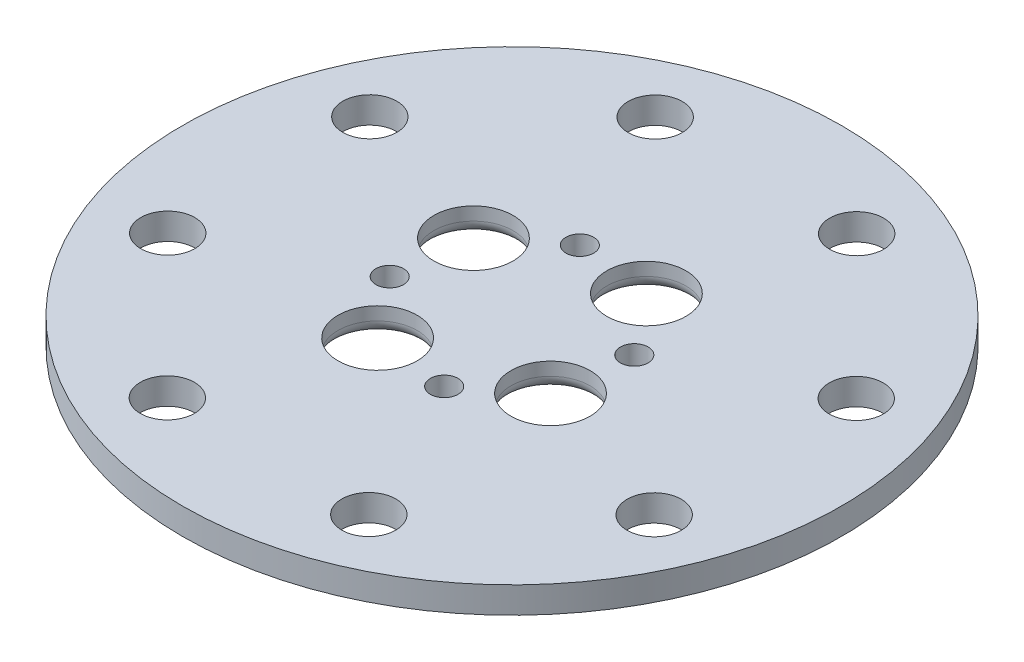
from build123d import *

# Parameters (mm, degrees)
SKETCH1_R           = 25
BOSS_EXTRUDE1_DEPTH = 2
SKETCH2_R           = 1.05
SKETCH2_R_2         = 3
CUT_EXTRUDE1_DEPTH  = 3
FILLET1_R           = 1
SKETCH4_R           = 2.05
CUT_EXTRUDE3_DEPTH  = 3


with BuildPart() as part:
    # Sketch1 → Boss-Extrude1 (new body)
    with BuildSketch(Plane(origin=(0, 0, 0), x_dir=(1, 0, 0), z_dir=(0, 1, 0))):
        Circle(SKETCH1_R)
    extrude(amount=BOSS_EXTRUDE1_DEPTH)

    # Sketch2 → Cut-Extrude1 (cut, through all)
    with BuildSketch(Plane(origin=(0, 2, 0), x_dir=(1, 0, 0), z_dir=(0, 1, 0))):
        with Locations((-2.066368974, 7.209723938)):
            Circle(SKETCH2_R)
        with Locations((7.209723938, 2.066368974)):
            Circle(SKETCH2_R)
        with Locations((2.066368974, -7.209723938)):
            Circle(SKETCH2_R)
        with Locations((-7.209723938, -2.066368974)):
            Circle(SKETCH2_R)
        with Locations((-3.636901173, -6.559188201)):
            Circle(SKETCH2_R_2)
        with Locations((-6.559188201, 3.636901173)):
            Circle(SKETCH2_R_2)
        with Locations((3.636901173, 6.559188201)):
            Circle(SKETCH2_R_2)
        with Locations((6.559188201, -3.636901173)):
            Circle(SKETCH2_R_2)
    extrude(amount=-CUT_EXTRUDE1_DEPTH, mode=Mode.SUBTRACT)

    # Fillet1
    fillet1_edges = [part.edges().sort_by_distance(p)[0] for p in [
        (-6.636901173, 0, 6.559188201),
        (-9.559188201, 0, -3.636901173),
        (0.636901173, 0, -6.559188201),
        (3.559188201, 0, 3.636901173),
    ]]
    fillet(fillet1_edges, radius=FILLET1_R)

    # Sketch4 → Cut-Extrude3 (cut, through all)
    with BuildSketch(Plane.XZ):
        with Locations((-18.488747294, 7.626678405)):
            Circle(SKETCH4_R)
        with Locations((-7.680642569, 18.466394605)):
            Circle(SKETCH4_R)
        with Locations((7.626678405, 18.488747294)):
            Circle(SKETCH4_R)
        with Locations((18.466394605, 7.680642569)):
            Circle(SKETCH4_R)
        with Locations((18.488747294, -7.626678405)):
            Circle(SKETCH4_R)
        with Locations((7.680642569, -18.466394605)):
            Circle(SKETCH4_R)
        with Locations((-7.626678405, -18.488747294)):
            Circle(SKETCH4_R)
        with Locations((-18.466394605, -7.680642569)):
            Circle(SKETCH4_R)
    extrude(amount=-CUT_EXTRUDE3_DEPTH, mode=Mode.SUBTRACT)


solid = part.part
